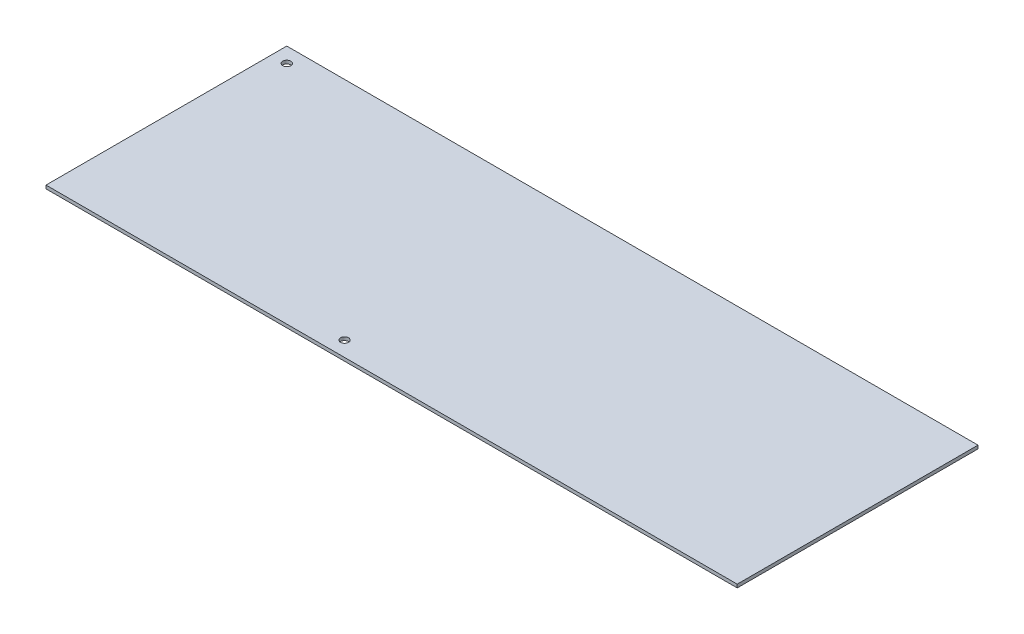
from build123d import *

# Parameters (mm, degrees)
SKETCH1_W           = 344.4875
SKETCH1_H           = 120
SKETCH1_R           = 2
BOSS_EXTRUDE1_DEPTH = 1.65
SKETCH2_R           = 2
CUT_EXTRUDE1_DEPTH  = 10


with BuildPart() as part:
    # Sketch1 → Boss-Extrude1 (new body)
    with BuildSketch(Plane(origin=(0, 0, 0), x_dir=(1, 0, 0), z_dir=(0, 1, 0))):
        with Locations((172.24375, 60)):
            Rectangle(SKETCH1_W, SKETCH1_H)
        with Locations((141.2875, 7.5)):
            Circle(SKETCH1_R, mode=Mode.SUBTRACT)
    extrude(amount=BOSS_EXTRUDE1_DEPTH)

    # Sketch2 → Cut-Extrude1 (cut)
    with BuildSketch(Plane(origin=(0, 1.65, 0), x_dir=(1, 0, 0), z_dir=(0, 1, 0))):
        with Locations((7.5, 112.5)):
            Circle(SKETCH2_R)
    extrude(amount=-CUT_EXTRUDE1_DEPTH, mode=Mode.SUBTRACT)


solid = part.part
